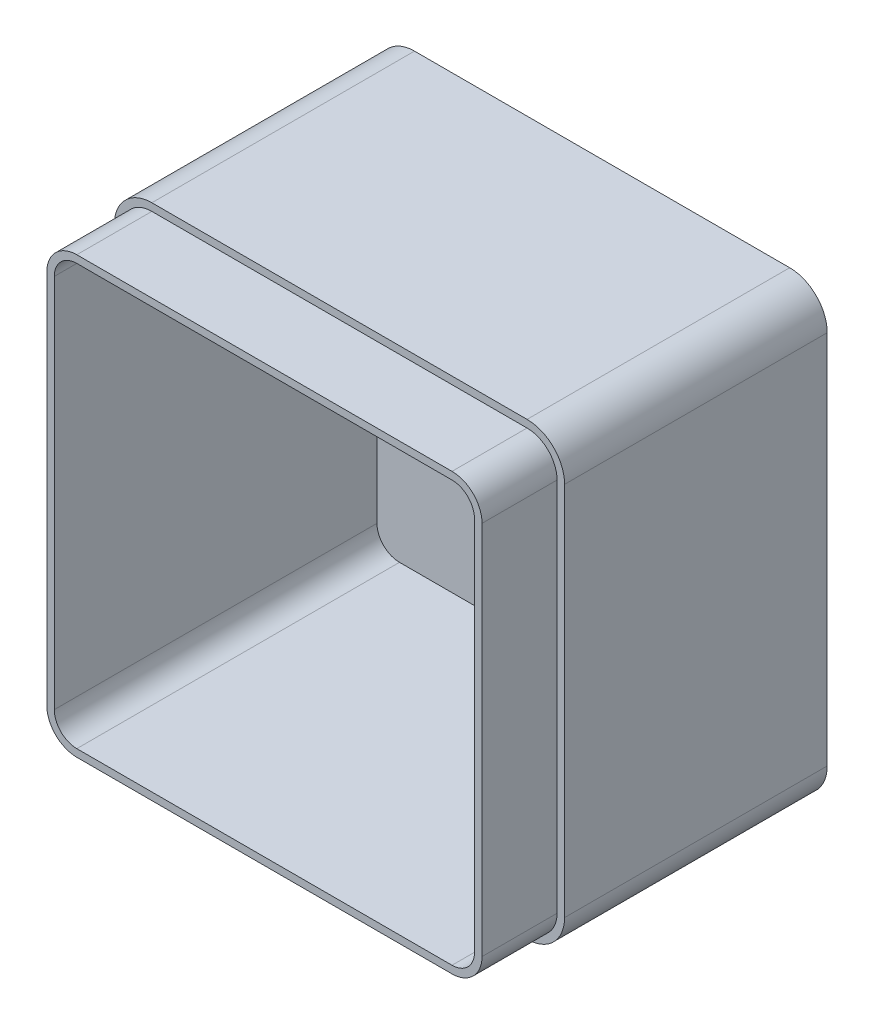
from build123d import *

# Parameters (mm, degrees)
SKETCH1_W           = 120
SKETCH1_H           = 120
BOSS_EXTRUDE1_DEPTH = 90
FILLET1_R           = 10
SHELL1_T            = -4
CUT_EXTRUDE2_DEPTH  = 20


with BuildPart() as part:
    # Sketch1 → Boss-Extrude1 (new body)
    with BuildSketch(Plane.XY):
        with Locations((60, 60)):
            Rectangle(SKETCH1_W, SKETCH1_H)
    extrude(amount=BOSS_EXTRUDE1_DEPTH)

    # Fillet1
    fillet1_edges = [part.edges().sort_by_distance(p)[0] for p in [
        (0, 120, 45),
        (120, 120, 45),
        (120, 0, 45),
        (0, 0, 45),
    ]]
    fillet(fillet1_edges, radius=FILLET1_R)

    # Shell1
    shell1_openings = [part.faces().sort_by_distance(p)[0] for p in [
        (60, 60, 90),
    ]]
    offset(amount=SHELL1_T, openings=shell1_openings, kind=Kind.INTERSECTION)

    # Sketch2 → Cut-Extrude2 (cut)
    with BuildSketch(Plane.XY.offset(90)):
        with BuildLine():
            Line((0, 110), (0, 10))
            ThreePointArc((0, 10), (2.928932188, 2.928932188), (10, 0))
            Line((10, 0), (110, 0))
            ThreePointArc((110, 0), (117.071067812, 2.928932188), (120, 10))
            Line((120, 10), (120, 110))
            ThreePointArc((120, 110), (117.071067812, 117.071067812), (110, 120))
            Line((110, 120), (10, 120))
            ThreePointArc((10, 120), (2.928932188, 117.071067812), (0, 110))
        make_face()
        with BuildLine():
            Line((2, 110), (2, 10))
            ThreePointArc((2, 10), (4.343145751, 4.343145751), (10, 2))
            Line((10, 2), (110, 2))
            ThreePointArc((110, 2), (115.656854249, 4.343145751), (118, 10))
            Line((118, 10), (118, 110))
            ThreePointArc((118, 110), (115.656854249, 115.656854249), (110, 118))
            Line((110, 118), (10, 118))
            ThreePointArc((10, 118), (4.343145751, 115.656854249), (2, 110))
        make_face(mode=Mode.SUBTRACT)
    extrude(amount=-CUT_EXTRUDE2_DEPTH, mode=Mode.SUBTRACT)


solid = part.part
